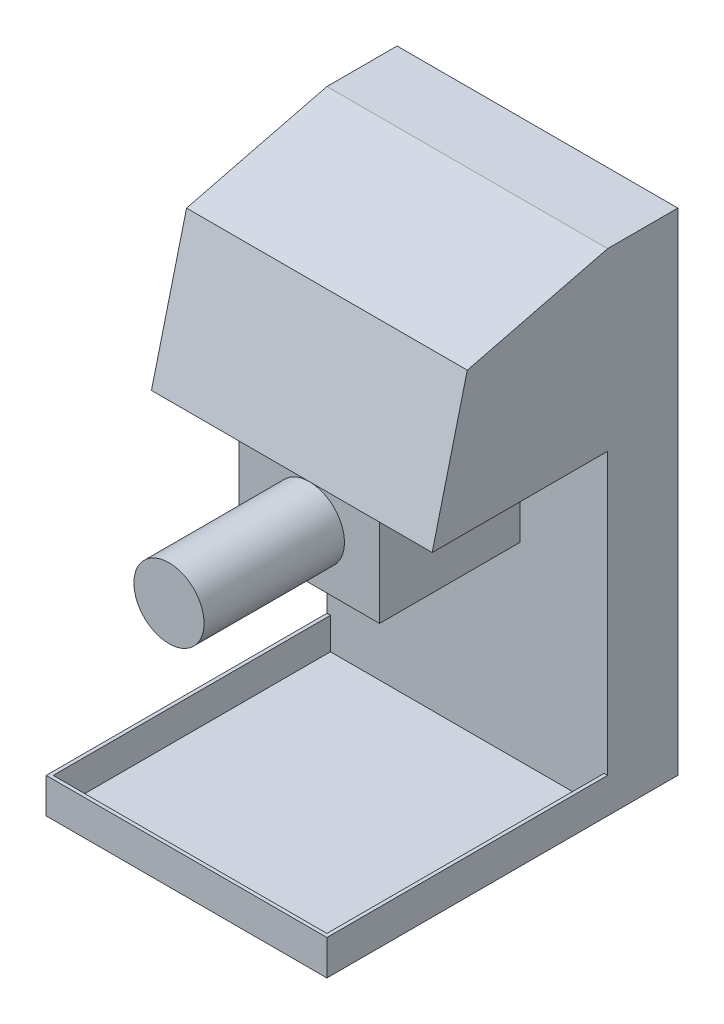
from build123d import *

# Parameters (mm, degrees)
BOSS_EXTRUDE1_DEPTH = 80
SKETCH2_W           = 40
SKETCH2_H           = 40
BOSS_EXTRUDE2_DEPTH = 30
SKETCH3_R           = 10
BOSS_EXTRUDE3_DEPTH = 40
SKETCH4_W           = 78
SKETCH4_H           = 79
CUT_EXTRUDE1_DEPTH  = 9


with BuildPart() as part:
    # Sketch1 → Boss-Extrude1 (new body)
    with BuildSketch(Plane(origin=(0, 0, 0), x_dir=(0, 0, -1), z_dir=(1, 0, 0))):
        Polygon((0, 0), (0, 140), (-20, 140), (-60, 130), (-70, 90), (-20, 90), (-20, 10), (-100, 10), (-100, 0), align=None)
    extrude(amount=BOSS_EXTRUDE1_DEPTH)

    # Sketch2 → Boss-Extrude2 (add)
    with BuildSketch(Plane.XZ.offset(-90)):
        with Locations((40, 45)):
            Rectangle(SKETCH2_W, SKETCH2_H)
    extrude(amount=BOSS_EXTRUDE2_DEPTH)

    # Sketch3 → Boss-Extrude3 (add)
    with BuildSketch(Plane.XY.offset(65)):
        with Locations(Location((40, 75, 0), (0, 0, 180))):  # turned: the seam where the file's is
            Circle(SKETCH3_R)
    extrude(amount=BOSS_EXTRUDE3_DEPTH)

    # Sketch4 → Cut-Extrude1 (cut)
    with BuildSketch(Plane(origin=(0, 10, 0), x_dir=(1, 0, 0), z_dir=(0, 1, 0))):
        with Locations((40, -59.5)):
            Rectangle(SKETCH4_W, SKETCH4_H)
    extrude(amount=-CUT_EXTRUDE1_DEPTH, mode=Mode.SUBTRACT)


solid = part.part
